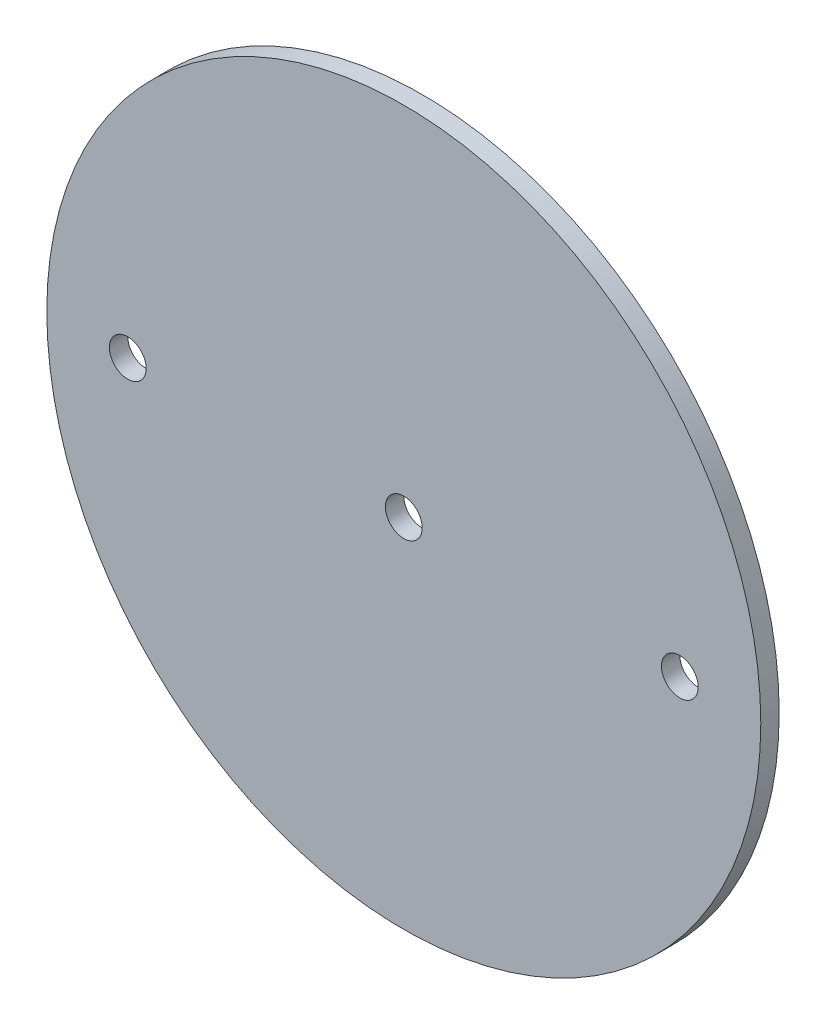
from build123d import *

# Parameters (mm, degrees)
SKETCH1_R                   = 61.595
BOSS_EXTRUDE1_DEPTH         = 1.5875
F_1_4_0_25_DIAMETER_HOLE1_D = 6.35


with BuildPart() as part:
    # Sketch1 → Boss-Extrude1 (new body, symmetric)
    with BuildSketch(Plane.XY):
        Circle(SKETCH1_R)
    extrude(amount=BOSS_EXTRUDE1_DEPTH, both=True)

    # 1/4 (0.25) Diameter Hole1 (through all)
    with Locations(Plane.XY.offset(1.5875)):
        with Locations((-47.625, 0), (0, 0), (47.625, 0)):
            Hole(F_1_4_0_25_DIAMETER_HOLE1_D / 2)


solid = part.part
